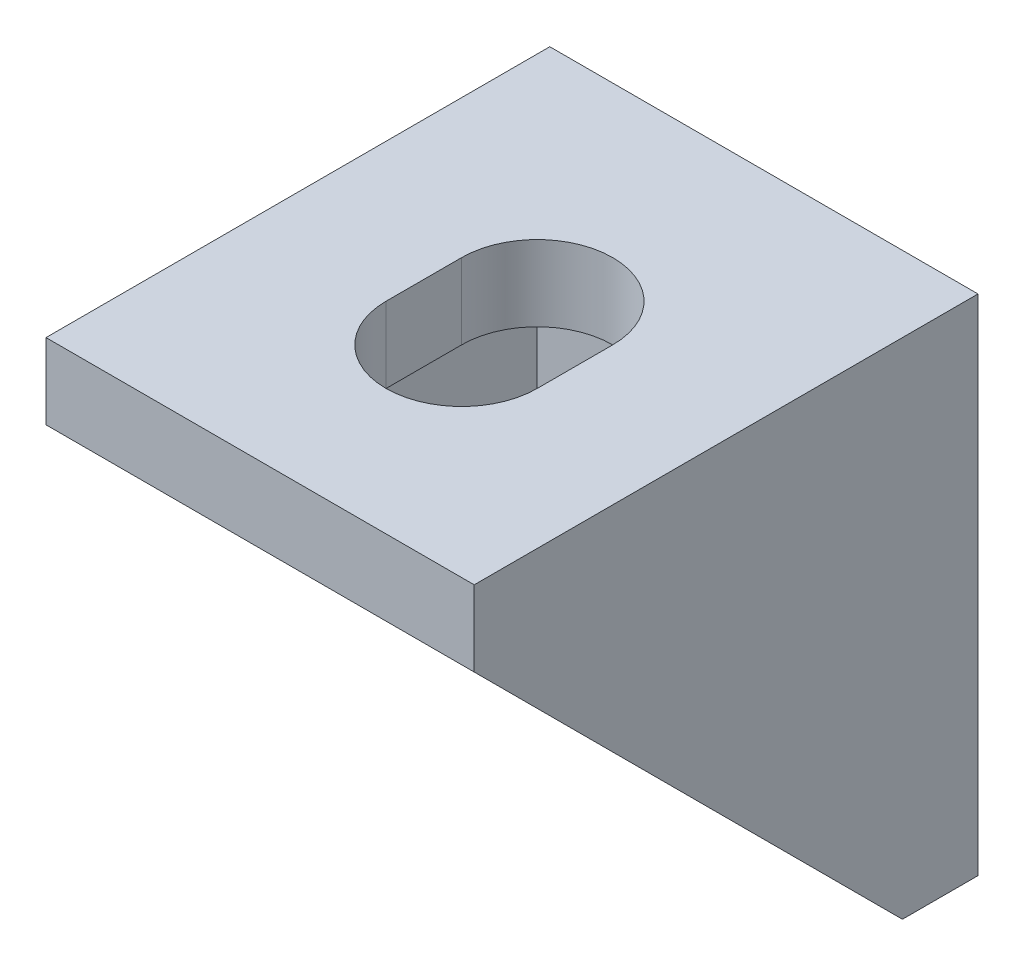
from build123d import *

# Parameters (mm, degrees)
BOSS_EXTRUDE1_DEPTH = 8.5
SKETCH2_W           = 17
SKETCH2_H           = 17
CUT_EXTRUDE1_DEPTH  = 6
CUT_EXTRUDE2_DEPTH  = 3


with BuildPart() as part:
    # Sketch1 → Boss-Extrude1 (new body, symmetric)
    with BuildSketch(Plane(origin=(0, 0, 0), x_dir=(0, 0, -1), z_dir=(1, 0, 0))):
        Polygon((0, 0), (-20, 0), (-20, -3), (-11.5, -11.5), (-3, -20), (0, -20), align=None)
    extrude(amount=BOSS_EXTRUDE1_DEPTH, both=True)

    # Sketch2 → Cut-Extrude1 (cut, symmetric)
    with BuildSketch(Plane(origin=(0, 0, 0), x_dir=(0, 0, -1), z_dir=(1, 0, 0))):
        with Locations((-11.5, -11.5)):
            Rectangle(SKETCH2_W, SKETCH2_H)
    extrude(amount=CUT_EXTRUDE1_DEPTH, both=True, mode=Mode.SUBTRACT)

    # Sketch3 → Cut-Extrude2 (cut)
    with BuildSketch(Plane.XY.offset(3)):
        with BuildLine():
            Line((-3, -9), (-3, -12))
            ThreePointArc((-3, -12), (0, -15), (3, -12))
            Line((3, -12), (3, -9))
            ThreePointArc((3, -9), (0, -6), (-3, -9))
        make_face()
    cut_extrude2 = extrude(amount=-CUT_EXTRUDE2_DEPTH, mode=Mode.SUBTRACT)

    # Mirror1: Cut-Extrude2 across plane
    add(cut_extrude2.mirror(Plane(origin=(0, 0, 0), x_dir=(0, -0.707106781, 0.707106781), z_dir=(0, 0.707106781, 0.707106781))), mode=Mode.SUBTRACT)


solid = part.part
